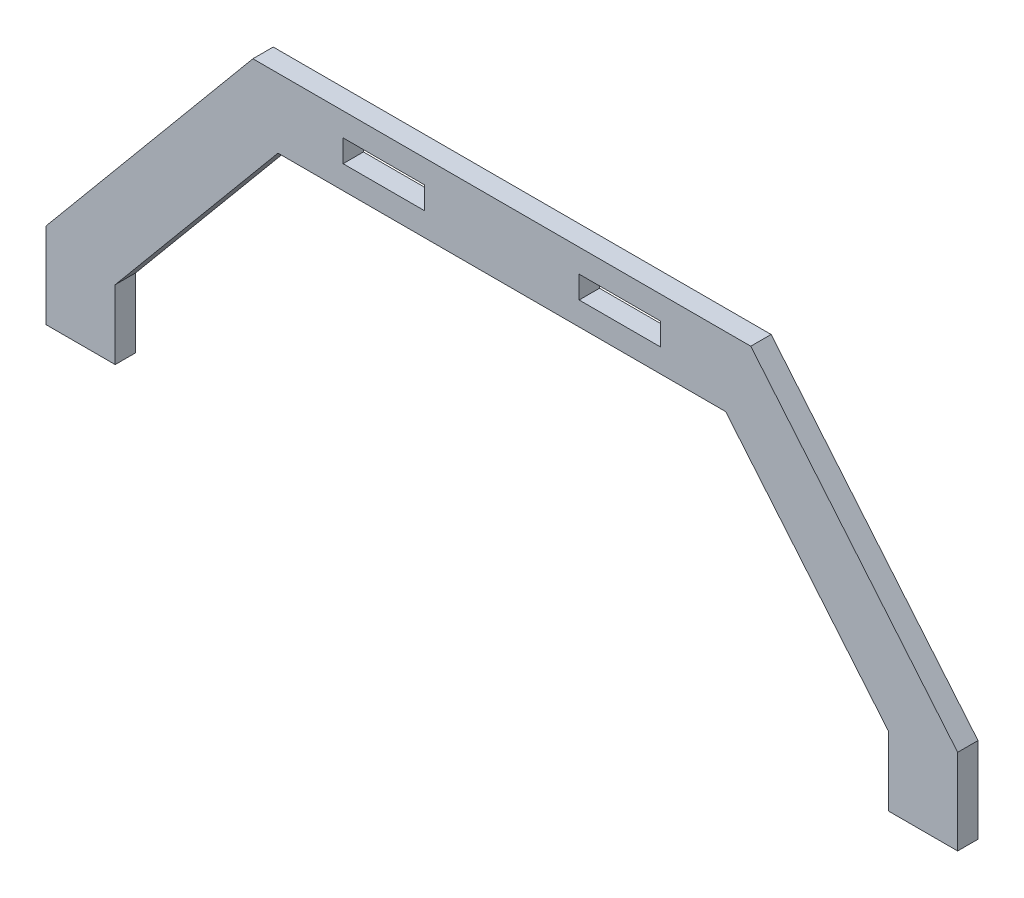
from build123d import *

# Parameters (mm, degrees)
SKETCH1_W           = 20
SKETCH1_H           = 5.5
BOSS_EXTRUDE1_DEPTH = 5


with BuildPart() as part:
    # Sketch1 → Boss-Extrude1 (new body)
    with BuildSketch(Plane.XY):
        Polygon((-112, 0), (-95, 0), (-95, 17), (-55, 65), (55, 65), (95, 17), (95, 0), (112, 0), (112, 21), (61.166666667, 82), (-61.166666667, 82), (-112, 21), align=None)
        with Locations((29, 73.5)):
            Rectangle(SKETCH1_W, SKETCH1_H, mode=Mode.SUBTRACT)
        with Locations((-29, 73.5)):
            Rectangle(SKETCH1_W, SKETCH1_H, mode=Mode.SUBTRACT)
    extrude(amount=BOSS_EXTRUDE1_DEPTH)


solid = part.part
